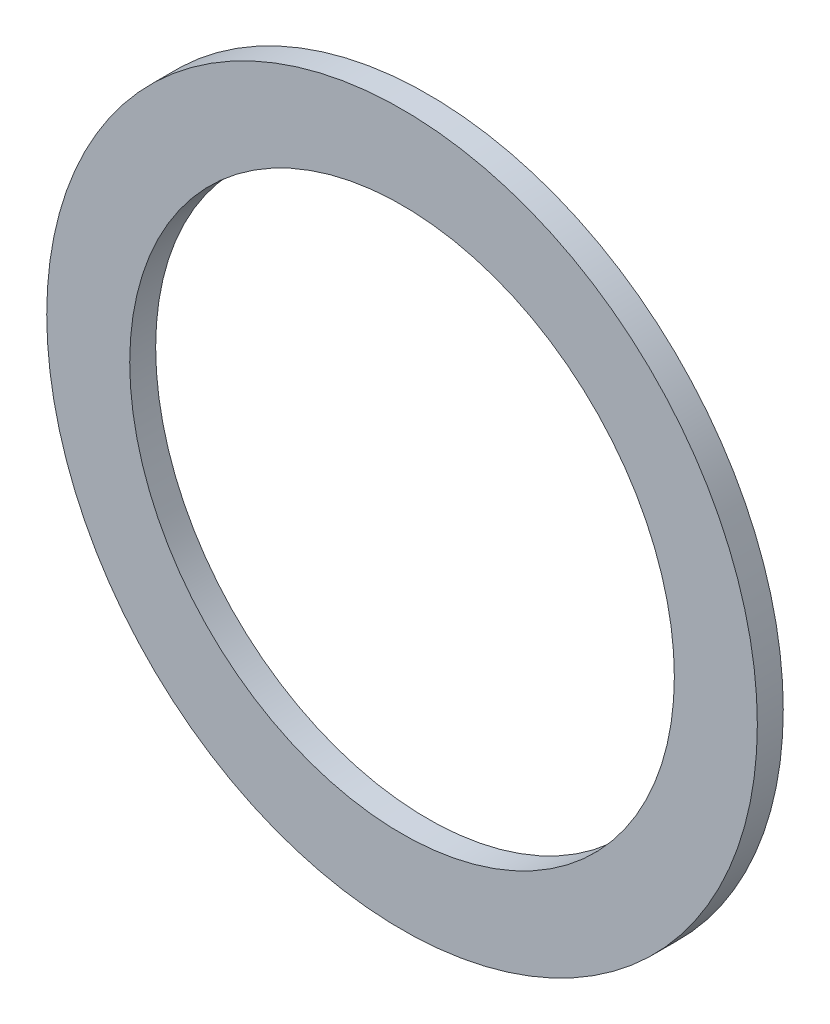
from build123d import *

# Parameters (mm, degrees)
BOSS_EXTRUDE1_DEPTH      = 1.27
BOSS_EXTRUDE1_DEPTH_BACK = 1.27
SKETCH1_W                = 74.549
SKETCH1_H                = 74.549
SKETCH1_R                = 26.67
SKETCH2_R                = 3.302
CUT_EXTRUDE1_DEPTH       = 53.775262202
MIRROR2_COPY_1_SKETCH_R  = 3.302
MIRROR2_COPY_1_DEPTH     = 53.775262202
MIRROR2_COPY_2_SKETCH_R  = 3.302
MIRROR2_COPY_2_DEPTH     = 53.775262202
SKETCH14_OUTSIDE_W       = 97.642
SKETCH14_OUTSIDE_H       = 97.642
SKETCH14_OUTSIDE_R       = 34.798
CUT_EXTRUDE6_DEPTH       = 53.775262202


with BuildPart() as part:
    # Sketch1 → Boss-Extrude1 (new, two sides: drawn at the far end of the back side and taken through both)
    with BuildSketch(Plane.XY.offset(-BOSS_EXTRUDE1_DEPTH_BACK)):
        Rectangle(SKETCH1_W, SKETCH1_H)
        Circle(SKETCH1_R, mode=Mode.SUBTRACT)
    extrude(amount=BOSS_EXTRUDE1_DEPTH + BOSS_EXTRUDE1_DEPTH_BACK)

    # Sketch2 → Cut-Extrude1 (cut, through all)
    with BuildSketch(Plane.XY.offset(1.27)):
        with Locations((-31.75, 31.75)):
            Circle(SKETCH2_R)
    cut_extrude1 = extrude(amount=-CUT_EXTRUDE1_DEPTH, mode=Mode.SUBTRACT)

    # Mirror1: Cut-Extrude1 across plane
    add(cut_extrude1.mirror(Plane(origin=(0, 0, 0), x_dir=(0, 0, 1), z_dir=(1, 0, 0))), mode=Mode.SUBTRACT)

    # Mirror2 copy 1 sketch → Mirror2 copy 1 (cut, through all)
    with BuildSketch(Plane(origin=(0, 0, 1.27), x_dir=(-1, 0, 0), z_dir=(0, 0, 1))):
        with Locations((-31.75, 31.75)):
            Circle(MIRROR2_COPY_1_SKETCH_R)
    extrude(amount=-MIRROR2_COPY_1_DEPTH, mode=Mode.SUBTRACT)

    # Mirror2 copy 2 sketch → Mirror2 copy 2 (cut, through all)
    with BuildSketch(Plane.XY.offset(1.27)):
        with Locations((-31.75, -31.75)):
            Circle(MIRROR2_COPY_2_SKETCH_R)
    extrude(amount=-MIRROR2_COPY_2_DEPTH, mode=Mode.SUBTRACT)

    # Sketch14 outside → Cut-Extrude6 (cut, through all)
    with BuildSketch(Plane.XY.offset(1.27)):
        Rectangle(SKETCH14_OUTSIDE_W, SKETCH14_OUTSIDE_H)
        Circle(SKETCH14_OUTSIDE_R, mode=Mode.SUBTRACT)
    extrude(amount=-CUT_EXTRUDE6_DEPTH, mode=Mode.SUBTRACT)


solid = part.part
